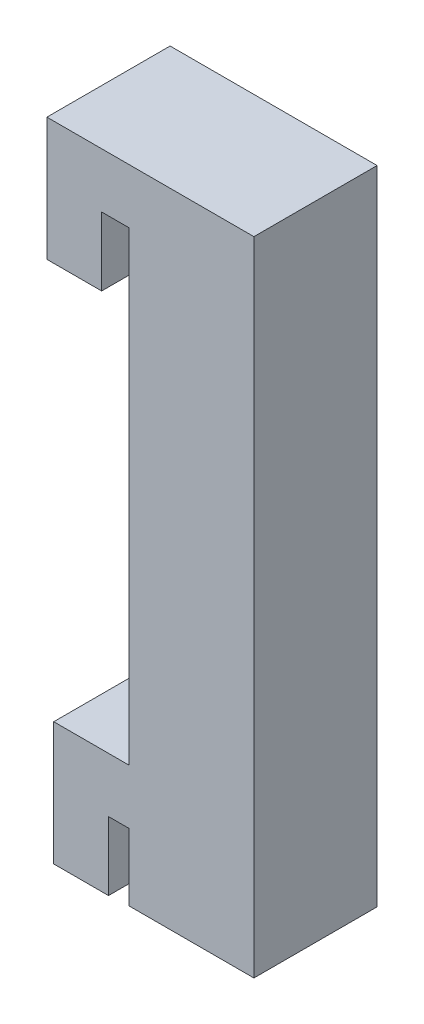
from build123d import *

# Parameters (mm, degrees)
BOSS_EXTRU_1_DEPTH = 9


with BuildPart() as part:
    # Esquisse1 → Boss.-Extru.1 (new body)
    with BuildSketch(Plane.XY):
        Polygon((0, 0), (0, 5), (1.5, 5), (1.5, 0.09638948), (10.621873618, 0.09638948), (10.621873618, 47), (-4.5, 47), (-4.5, 38), (-0.5, 38), (-0.5, 43), (1.5, 43), (1.5, 9), (-4, 9), (-4, 0), align=None)
    extrude(amount=BOSS_EXTRU_1_DEPTH)


solid = part.part
